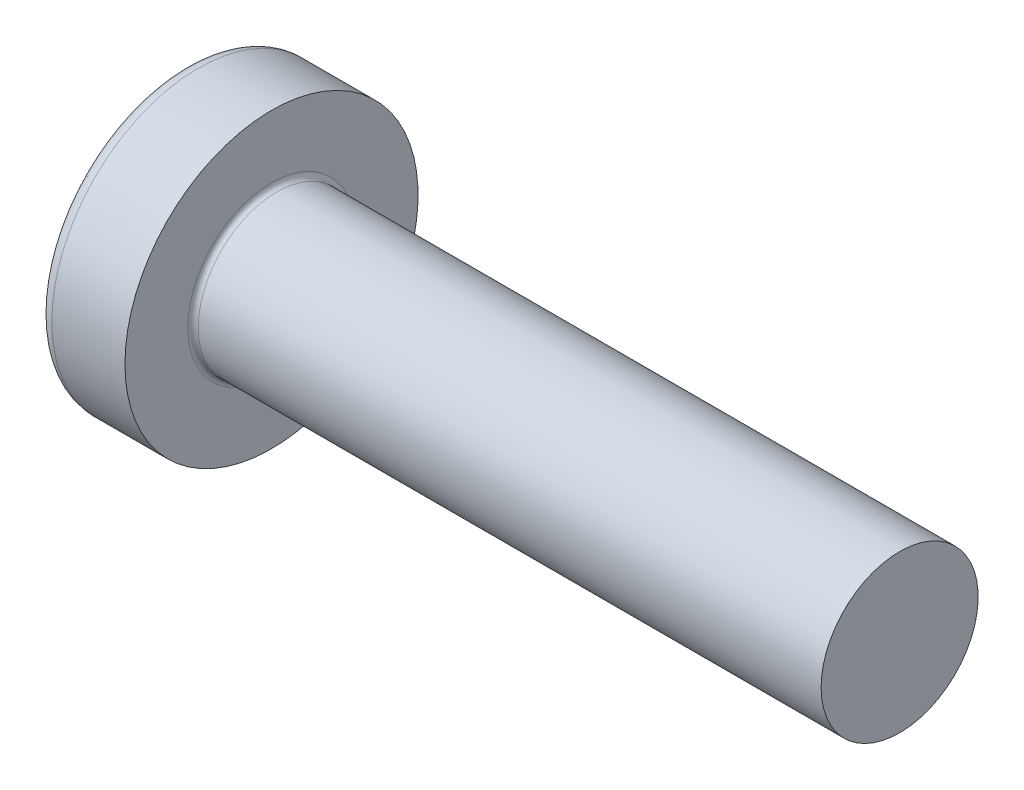
from build123d import *

# Parameters (mm, degrees)
FILLET1_R    = 0.1
SKETCH3_W    = 0.74
SKETCH3_H    = 2.8
SKETCH4_W    = 0.74
SKETCH4_H    = 1.054964664
RECPAT_COUNT = 2
RECPAT_ANGLE = 90


with BuildPart() as part:
    # BodySke → Base-Revolve (revolve)
    with BuildSketch(Plane.XY):
        with BuildLine():
            Line((2.4, 1.5), (2.4, 2.8))
            Line((2.4, 2.8), (1.003501533, 2.8))
            ThreePointArc((1.003501533, 2.8), (0.873295971, 2.76653015), (0.775371599, 2.674418605))
            ThreePointArc((0.775371599, 2.674418605), (0.197753546, 1.392274756), (0, 0))
            Line((0, 0), (14.4, 0))
            Line((14.4, 0), (14.4, 1.5))
            Line((14.4, 1.5), (2.4, 1.5))
        make_face()
    revolve(axis=Axis((-25.4, 0, 0), (1, 0, 0)))

    # Fillet1
    fillet1_edges = [part.edges().sort_by_distance(p)[0] for p in [
        (2.4, -1.5, 0),
    ]]
    fillet(fillet1_edges, radius=FILLET1_R)

    # Sketch3 → Recess section 0
    with BuildSketch(Plane(origin=(0, 0, 0), x_dir=(0, 0, -1), z_dir=(1, 0, 0))):
        Rectangle(SKETCH3_W, SKETCH3_H)
    # Sketch4 → Recess section 1
    with BuildSketch(Plane(origin=(1.75, 0, 0), x_dir=(0, 0, -1), z_dir=(1, 0, 0))):
        Rectangle(SKETCH4_W, SKETCH4_H)
    recess = loft(mode=Mode.SUBTRACT)

    # RecPat: Recess ×2 about axis
    recpat_axis = Axis((0, 0, 0), (1, 0, 0))
    for i in range(1, RECPAT_COUNT):
        add(recess.rotate(recpat_axis, i * RECPAT_ANGLE / (RECPAT_COUNT - 1)), mode=Mode.SUBTRACT)

    # RecCorSke → RecessCore (revolve, cut)
    with BuildSketch(Plane.XY):
        Polygon((0, 0), (0, 0.678371921), (1.75, 0.556), (1.930655351, 0), align=None)
    revolve(axis=Axis((-3.175, 0, 0), (1, 0, 0)), mode=Mode.SUBTRACT)


solid = part.part
